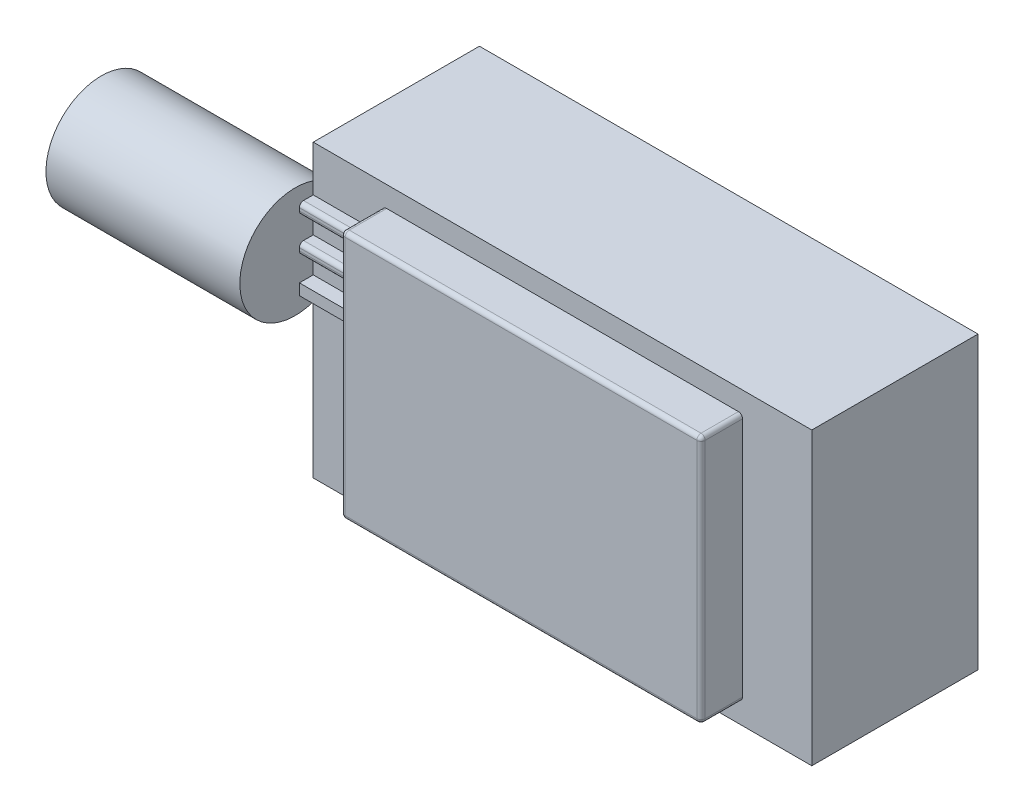
from build123d import *

# Parameters (mm, degrees)
SKICA1_W                 = 36
SKICA1_H                 = 21
P_IDAT_VYSUNUT_M1_DEPTH  = 15
SKICA2_W                 = 40.125032636
SKICA2_H                 = 25.475200522
SKICA2_W_2               = 26
SKICA2_H_2               = 18
ODEBRAT_VYSUNUT_M1_DEPTH = 3
SKICA3_R                 = 4
P_IDAT_VYSUNUT_M2_DEPTH  = 14
SKICA4_W                 = 4.119571066
SKICA4_H                 = 0.8
P_IDAT_VYSUNUT_M3_DEPTH  = 1
ZAOBLIT3_R               = 0.3


with BuildPart() as part:
    # Skica1 → Přidat vysunutím1 (new body)
    with BuildSketch(Plane.XY):
        Rectangle(SKICA1_W, SKICA1_H)
    extrude(amount=P_IDAT_VYSUNUT_M1_DEPTH)

    # Skica2 → Odebrat vysunutím1 (cut)
    with BuildSketch(Plane.XY.offset(15)):
        Rectangle(SKICA2_W, SKICA2_H)
        Rectangle(SKICA2_W_2, SKICA2_H_2, mode=Mode.SUBTRACT)
    extrude(amount=-ODEBRAT_VYSUNUT_M1_DEPTH, mode=Mode.SUBTRACT)

    # Skica3 → Přidat vysunutím2 (add)
    with BuildSketch(Plane.ZY.offset(18)):
        with Locations((13.3, 4.3)):
            Circle(SKICA3_R)
    extrude(amount=P_IDAT_VYSUNUT_M2_DEPTH)

    # Skica4 → Přidat vysunutím3 (add)
    with BuildSketch(Plane.XY.offset(12)):
        with Locations((-15.940214467, 6.8)):
            Rectangle(SKICA4_W, SKICA4_H)
        with Locations((-15.940214467, 4.3)):
            Rectangle(SKICA4_W, SKICA4_H)
        with Locations((-15.940214467, 1.8)):
            Rectangle(SKICA4_W, SKICA4_H)
    extrude(amount=P_IDAT_VYSUNUT_M3_DEPTH)

    # Zaoblit3
    zaoblit3_edges = [part.edges().sort_by_distance(p)[0] for p in [
        (13, 0, 15),
        (13, -9, 13.5),
        (0, -9, 15),
        (-13, -9, 13.5),
        (-13, 0, 15),
        (-13, 9, 13.5),
        (0, 9, 15),
        (13, 9, 13.5),
        (-13.880428934, 6.4, 12.5),
        (-13.880428934, 7.2, 12.5),
        (-15.940214467, 6.4, 13),
        (-13.880428934, 6.8, 13),
        (-15.940214467, 7.2, 13),
        (-13.880428934, 4.7, 12.5),
        (-13.880428934, 3.9, 12.5),
        (-15.940214467, 4.7, 13),
        (-15.940214467, 3.9, 13),
        (-13.880428934, 4.3, 13),
    ]]
    fillet(zaoblit3_edges, radius=ZAOBLIT3_R)


solid = part.part
